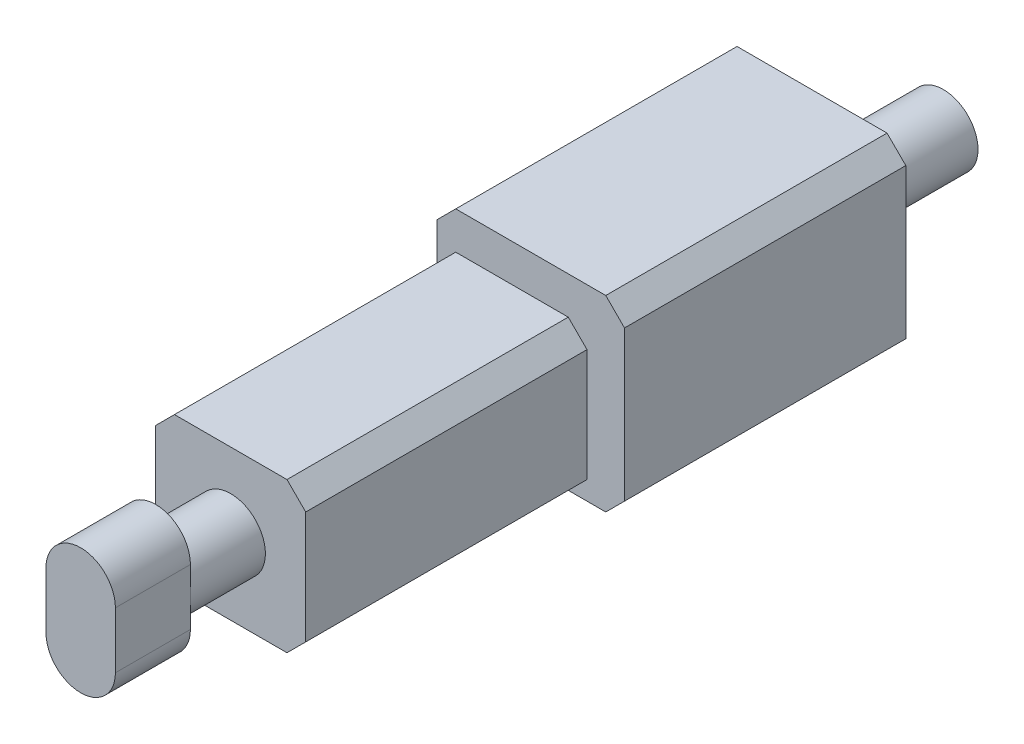
from build123d import *

# Parameters (mm, degrees)
SKETCH1_W           = 4
SKETCH1_H           = 15
BOSS_EXTRUDE1_DEPTH = 4
SKETCH2_R           = 0.925
BOSS_EXTRUDE2_DEPTH = 2
BOSS_EXTRUDE3_DEPTH = 2
SKETCH6_W           = 5
SKETCH6_H           = 5
BOSS_EXTRUDE5_DEPTH = 7.5
SKETCH7_R           = 0.925
BOSS_EXTRUDE6_DEPTH = 18
CHAMFER1_SIZE       = 0.5


with BuildPart() as part:
    # Sketch1 → Boss-Extrude1 (new body)
    with BuildSketch(Plane(origin=(0, 0, 0), x_dir=(1, 0, 0), z_dir=(0, 1, 0))):
        Rectangle(SKETCH1_W, SKETCH1_H)
    extrude(amount=BOSS_EXTRUDE1_DEPTH)

    # Sketch2 → Boss-Extrude2 (add)
    with BuildSketch(Plane.XY.offset(7.5)):
        with Locations((0, 2)):
            Circle(SKETCH2_R)
    extrude(amount=BOSS_EXTRUDE2_DEPTH)

    # Sketch3 → Boss-Extrude3 (add)
    with BuildSketch(Plane.XY.offset(9.5)):
        with BuildLine():
            Line((-0.925, 1.25), (-0.925, 2.75))
            ThreePointArc((-0.925, 2.75), (0, 3.675), (0.925, 2.75))
            Line((0.925, 2.75), (0.925, 1.25))
            ThreePointArc((0.925, 1.25), (0, 0.325), (-0.925, 1.25))
        make_face()
    extrude(amount=BOSS_EXTRUDE3_DEPTH)

    # Sketch6 → Boss-Extrude5 (add)
    with BuildSketch(Plane.XY):
        with Locations((0.5, 2.5)):
            Rectangle(SKETCH6_W, SKETCH6_H)
    extrude(amount=-BOSS_EXTRUDE5_DEPTH)

    # Sketch7 → Boss-Extrude6 (add)
    with BuildSketch(Plane.XY.offset(7.5)):
        with Locations((1, 2.832903413)):
            Circle(SKETCH7_R)
    extrude(amount=-BOSS_EXTRUDE6_DEPTH)

    # Chamfer1
    chamfer1_edges = [part.edges().sort_by_distance(p)[0] for p in [
        (-2, 4, 3.75),
        (3, 0, -3.75),
        (-2, 5, -3.75),
        (3, 5, -3.75),
        (2, 4, 3.75),
        (-2, 0, 0),
        (2, 0, 3.75),
    ]]
    chamfer(chamfer1_edges, length=CHAMFER1_SIZE)


solid = part.part
